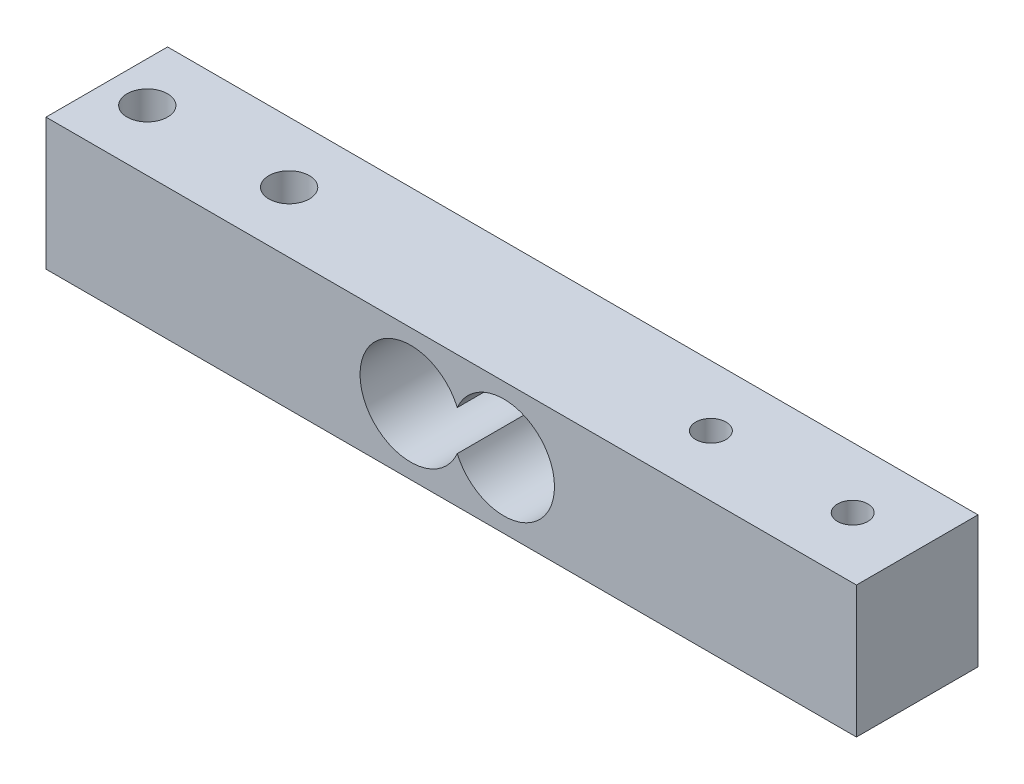
from build123d import *

# Parameters (mm, degrees)
SKETCH2_W               = 80
SKETCH2_H               = 12
BOSS_EXTRUDE1_DEPTH     = 13
SKETCH3_R               = 2
SKETCH3_R_2             = 1.5
CUT_EXTRUDE1_DEPTH      = 13
SKETCH4_R               = 5
CUT_EXTRUDE2_DEPTH      = 6.5
CUT_EXTRUDE2_DEPTH_BACK = 6.5


with BuildPart() as part:
    # Sketch2 → Boss-Extrude1 (new body)
    with BuildSketch(Plane(origin=(0, 0, 0), x_dir=(1, 0, 0), z_dir=(0, 1, 0))):
        Rectangle(SKETCH2_W, SKETCH2_H)
    extrude(amount=BOSS_EXTRUDE1_DEPTH)

    # Sketch3 → Cut-Extrude1 (cut)
    with BuildSketch(Plane(origin=(0, 0, 0), x_dir=(1, 0, 0), z_dir=(0, 1, 0))):
        with Locations((-36, 0)):
            Circle(SKETCH3_R)
        with Locations((-22, 0)):
            Circle(SKETCH3_R)
        with Locations((33.631617814, 0)):
            Circle(SKETCH3_R_2)
        with Locations((19.631617814, 0)):
            Circle(SKETCH3_R_2)
    extrude(amount=CUT_EXTRUDE1_DEPTH, mode=Mode.SUBTRACT)

    # Sketch4 → Cut-Extrude2 (cut, two sides)
    with BuildSketch(Plane.XY) as cut_extrude2_sk:
        with Locations((-4, 6.5)):
            Circle(SKETCH4_R)
        with Locations((5.193549115, 6.5)):
            Circle(SKETCH4_R)
    extrude(amount=CUT_EXTRUDE2_DEPTH, mode=Mode.SUBTRACT)
    extrude(cut_extrude2_sk.sketch, amount=-CUT_EXTRUDE2_DEPTH_BACK, mode=Mode.SUBTRACT)


solid = part.part
